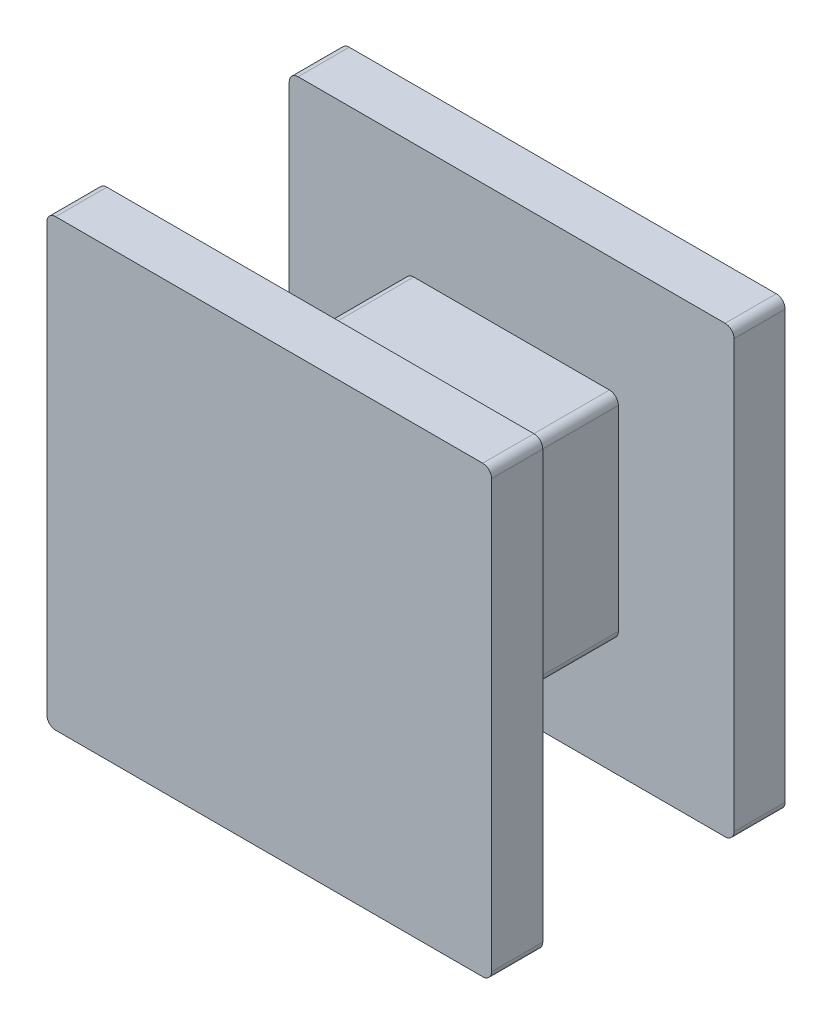
from build123d import *

# Parameters (mm, degrees)
SKETCH2_W           = 4.8
SKETCH2_H           = 4.8
BOSS_EXTRUDE1_DEPTH = 4.3
SKETCH3_W           = 10
SKETCH3_H           = 10
BOSS_EXTRUDE2_DEPTH = 1.15
SKETCH4_W           = 10
SKETCH4_H           = 10
BOSS_EXTRUDE4_DEPTH = 1.15
FILLET2_R           = 0.2


with BuildPart() as part:
    # Sketch2 → Boss-Extrude1 (new body)
    with BuildSketch(Plane.XY):
        with Locations((2.4, -2.4)):
            Rectangle(SKETCH2_W, SKETCH2_H)
    extrude(amount=BOSS_EXTRUDE1_DEPTH)

    # Sketch3 → Boss-Extrude2 (add)
    with BuildSketch(Plane.XY.offset(4.3)):
        with Locations((2.4, -2.4)):
            Rectangle(SKETCH3_W, SKETCH3_H)
    extrude(amount=BOSS_EXTRUDE2_DEPTH)

    # Sketch4 → Boss-Extrude4 (add)
    with BuildSketch(Plane(origin=(0, 0, 0), x_dir=(-1, 0, 0), z_dir=(0, 0, -1))):
        with Locations((-2.4, -2.4)):
            Rectangle(SKETCH4_W, SKETCH4_H)
    extrude(amount=BOSS_EXTRUDE4_DEPTH)

    # Fillet2
    fillet2_edges = [part.edges().sort_by_distance(p)[0] for p in [
        (-2.6, 2.6, 4.875),
        (-2.6, -7.4, 4.875),
        (7.4, -7.4, 4.875),
        (7.4, 2.6, 4.875),
        (7.4, 2.6, -0.575),
        (7.4, -7.4, -0.575),
        (-2.6, -7.4, -0.575),
        (-2.6, 2.6, -0.575),
        (0, 0, 2.15),
        (4.8, 0, 2.15),
        (4.8, -4.8, 2.15),
        (0, -4.8, 2.15),
    ]]
    fillet(fillet2_edges, radius=FILLET2_R)


solid = part.part
